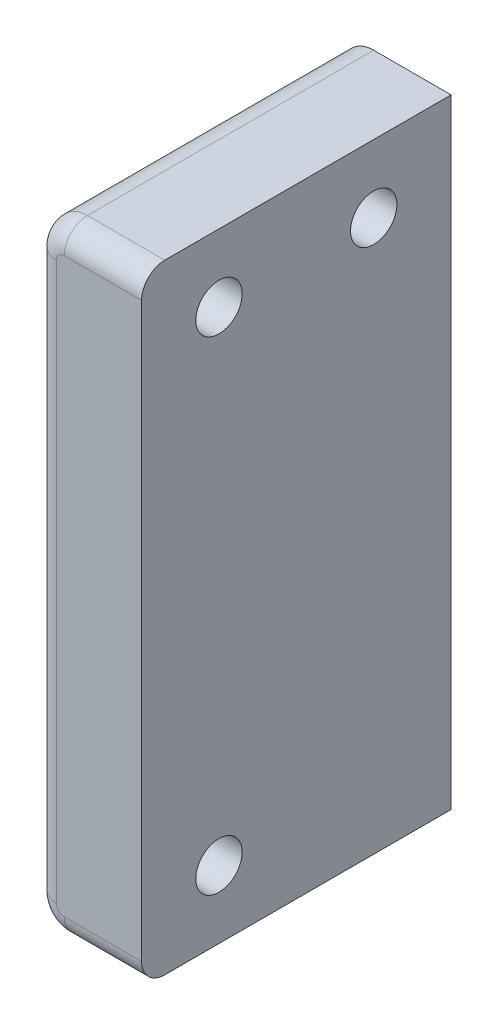
from build123d import *

# Parameters (mm, degrees)
BOSS_EXTRUDE1_DEPTH = 20
SKETCH3_R           = 1.5
CUT_EXTRUDE1_DEPTH  = 10
FILLET1_R           = 1.5


with BuildPart() as part:
    # Sketch2 → Boss-Extrude1 (new body)
    with BuildSketch(Plane.XY):
        with BuildLine():
            Line((-148, -28), (-153, -28))
            ThreePointArc((-153, -28), (-154.414213562, -28.585786438), (-155, -30))
            Line((-155, -30), (-155, -66))
            ThreePointArc((-155, -66), (-154.414213562, -67.414213562), (-153, -68))
            Line((-153, -68), (-148, -68))
            Line((-148, -68), (-148, -28))
        make_face()
    extrude(amount=BOSS_EXTRUDE1_DEPTH)

    # Sketch3 → Cut-Extrude1 (cut)
    with BuildSketch(Plane(origin=(-148, 0, 0), x_dir=(0, 0, -1), z_dir=(1, 0, 0))):
        with Locations((-15, -63.625)):
            Circle(SKETCH3_R)
        with Locations((-5, -32.375)):
            Circle(SKETCH3_R)
        with Locations((-15, -32.375)):
            Circle(SKETCH3_R)
    extrude(amount=-CUT_EXTRUDE1_DEPTH, mode=Mode.SUBTRACT)

    # Fillet1
    fillet1_edges = [part.edges().sort_by_distance(p)[0] for p in [
        (-150.5, -68, 20),
        (-150.5, -28, 20),
        (-154.414213562, -28.585786438, 20),
        (-155, -48, 20),
        (-154.414213562, -67.414213562, 20),
    ]]
    fillet(fillet1_edges, radius=FILLET1_R)


solid = part.part
